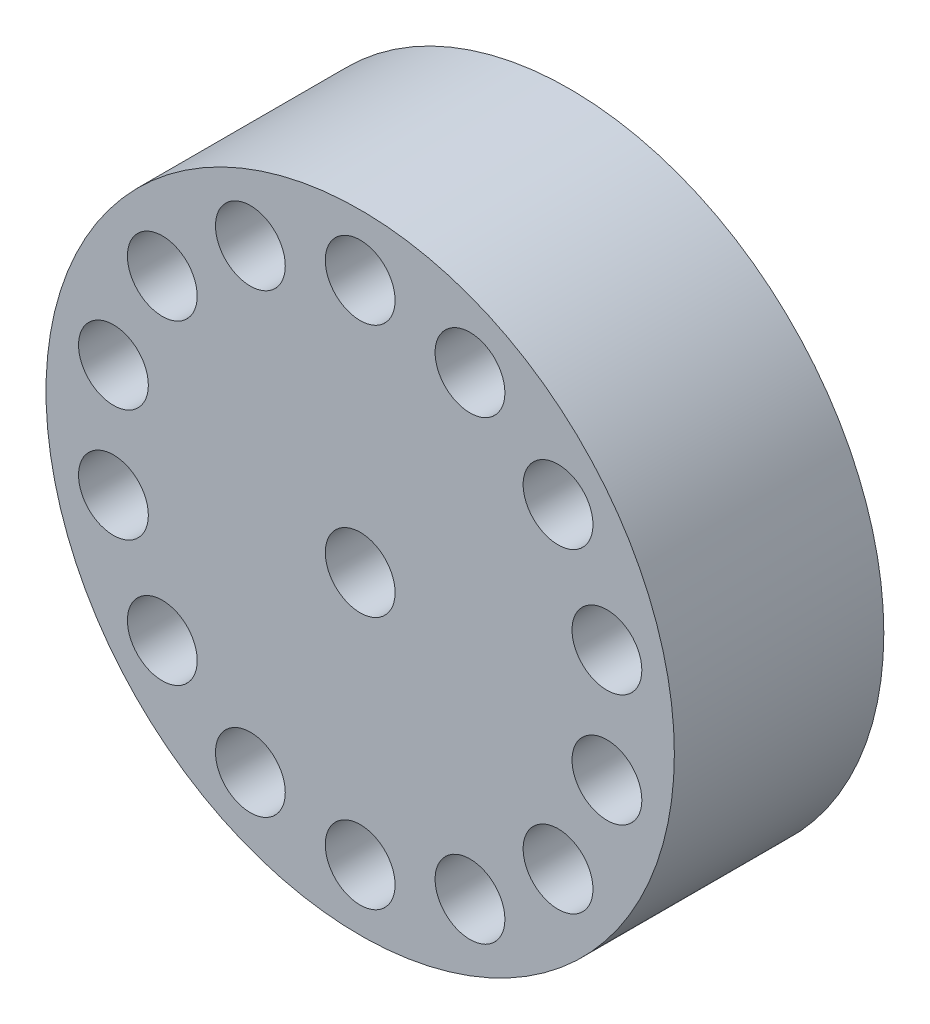
from build123d import *

# Parameters (mm, degrees)
SZKIC1_R                    = 4.5
SZKIC1_R_2                  = 0.5
DODANIE_WYCI_GNI_CIE1_DEPTH = 3
SZKIC2_R                    = 0.5
WYTNIJ_WYCI_GNI_CIE1_DEPTH  = 1


with BuildPart() as part:
    # Szkic1 → Dodanie-wyciągnięcie1 (new body)
    with BuildSketch(Plane.XY):
        Circle(SZKIC1_R)
        Circle(SZKIC1_R_2, mode=Mode.SUBTRACT)
    extrude(amount=DODANIE_WYCI_GNI_CIE1_DEPTH)

    # Szkic2 → Wytnij-wyciągnięcie1 (cut)
    with BuildSketch(Plane.XY.offset(3)):
        with Locations((0, 3.625)):
            Circle(SZKIC2_R)
        with Locations((1.572828554, 3.266012146)):
            Circle(SZKIC2_R)
        with Locations((2.834139124, 2.260150532)):
            Circle(SZKIC2_R)
        with Locations((3.534113682, 0.806638386)):
            Circle(SZKIC2_R)
        with Locations((3.534113682, -0.806638386)):
            Circle(SZKIC2_R)
        with Locations((2.834139124, -2.260150532)):
            Circle(SZKIC2_R)
        with Locations((1.572828554, -3.266012146)):
            Circle(SZKIC2_R)
        with Locations((0, -3.625)):
            Circle(SZKIC2_R)
        with Locations((-1.572828554, -3.266012146)):
            Circle(SZKIC2_R)
        with Locations((-2.834139124, -2.260150532)):
            Circle(SZKIC2_R)
        with Locations((-3.534113682, -0.806638386)):
            Circle(SZKIC2_R)
        with Locations((-3.534113682, 0.806638386)):
            Circle(SZKIC2_R)
        with Locations((-2.834139124, 2.260150532)):
            Circle(SZKIC2_R)
        with Locations((-1.572828554, 3.266012146)):
            Circle(SZKIC2_R)
    extrude(amount=-WYTNIJ_WYCI_GNI_CIE1_DEPTH, mode=Mode.SUBTRACT)


solid = part.part
